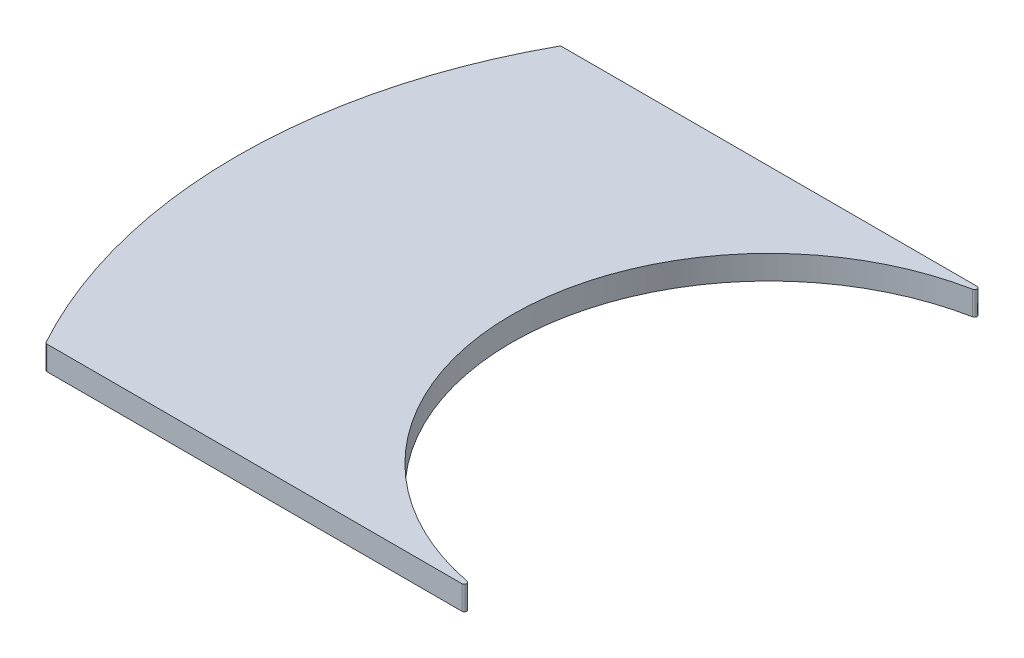
from build123d import *

# Parameters (mm, degrees)
BOSS_EXTRUDE1_DEPTH = 1
FILLET1_R           = 0.1
FILLET2_R           = 0.1
FILLET3_R           = 0.1
FILLET4_R           = 0.1


with BuildPart() as part:
    # Sketch1 → Boss-Extrude1 (new body)
    with BuildSketch(Plane(origin=(0, 0, 0), x_dir=(1, 0, 0), z_dir=(0, 1, 0))):
        with BuildLine():
            ThreePointArc((0, -10.76), (-10.76, 0), (0, 10.76))
            Line((0, 10.76), (-19.469525546, 10.76))
            ThreePointArc((-19.469525546, 10.76), (-22.245, 0), (-19.469525546, -10.76))
            Line((-19.469525546, -10.76), (0, -10.76))
        make_face()
    extrude(amount=BOSS_EXTRUDE1_DEPTH)

    # Fillet1
    fillet1_edges = [part.edges().sort_by_distance(p)[0] for p in [
        (0, 0.5, 10.76),
    ]]
    fillet(fillet1_edges, radius=FILLET1_R)

    # Fillet2
    fillet2_edges = [part.edges().sort_by_distance(p)[0] for p in [
        (0, 0.5, -10.76),
    ]]
    fillet(fillet2_edges, radius=FILLET2_R)

    # Fillet3
    fillet3_edges = [part.edges().sort_by_distance(p)[0] for p in [
        (-19.469525546, 0.5, 10.76),
    ]]
    fillet(fillet3_edges, radius=FILLET3_R)

    # Fillet4
    fillet4_edges = [part.edges().sort_by_distance(p)[0] for p in [
        (-19.469525546, 0.5, -10.76),
    ]]
    fillet(fillet4_edges, radius=FILLET4_R)


solid = part.part
